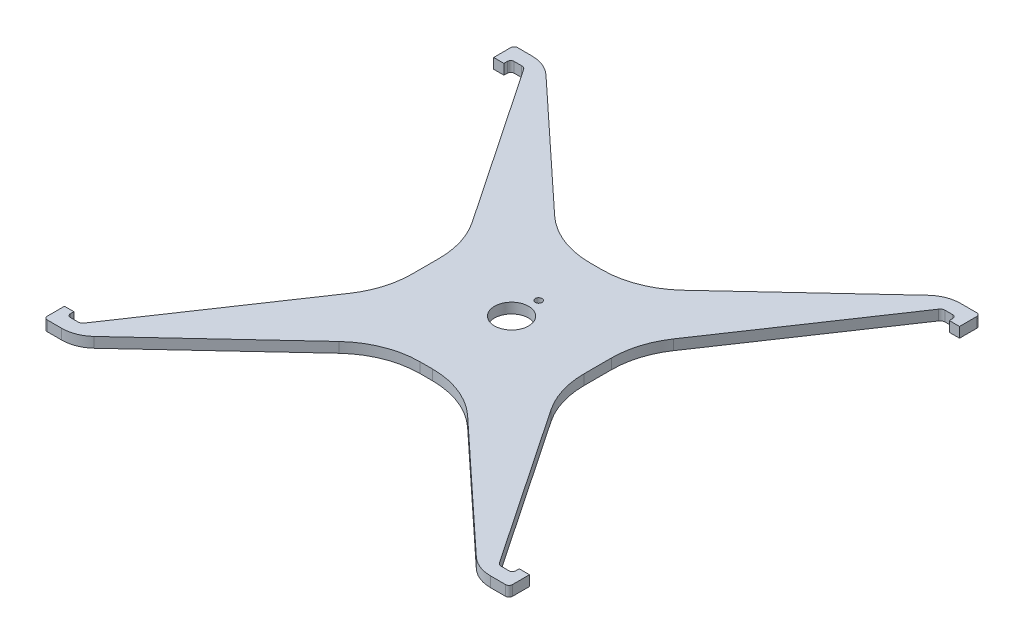
from build123d import *

# Parameters (mm, degrees)
SKETCH1_R           = 5
SKETCH1_R_2         = 1
BOSS_EXTRUDE1_DEPTH = 3


with BuildPart() as part:
    # Sketch1 → Boss-Extrude1 (new body)
    with BuildSketch(Plane(origin=(0, 0, 0), x_dir=(1, 0, 0), z_dir=(0, 1, 0))):
        with BuildLine():
            Line((-65.25, 63), (-68.25, 63))
            Line((-68.25, 63), (-68.25, 68))
            ThreePointArc((-68.25, 68), (-67.957106781, 68.707106781), (-67.25, 69))
            Line((-67.25, 69), (-63.058671293, 69))
            ThreePointArc((-63.058671293, 69), (-59.396555712, 68.305316194), (-56.243242609, 66.317781894))
            Line((-56.243242609, 66.317781894), (-19.079799162, 31.705545266))
            ThreePointArc((-19.079799162, 31.705545266), (-11.196516404, 26.736709515), (-2.04122745, 25))
            Line((-2.04122745, 25), (1.54122745, 25))
            ThreePointArc((1.54122745, 25), (10.696516404, 26.736709515), (18.579799162, 31.705545266))
            Line((18.579799162, 31.705545266), (55.743242609, 66.317781894))
            ThreePointArc((55.743242609, 66.317781894), (58.896555712, 68.305316194), (62.558671293, 69))
            Line((62.558671293, 69), (67.25, 69))
            ThreePointArc((67.25, 69), (67.957106781, 68.707106781), (68.25, 68))
            Line((68.25, 68), (68.25, 63))
            Line((68.25, 63), (65.25, 63))
            Line((65.25, 63), (65.25, 64))
            ThreePointArc((65.25, 64), (64.957106781, 64.707106781), (64.25, 65))
            Line((64.25, 65), (62.047564147, 65))
            ThreePointArc((62.047564147, 65), (61.343356803, 64.824421389), (60.804007789, 64.338789355))
            Line((60.804007789, 64.338789355), (29.524060686, 17.964360684))
            ThreePointArc((29.524060686, 17.964360684), (26.342381101, 11.293830715), (25.25, 3.984538097))
            Line((25.25, 3.984538097), (25.25, -3.984538097))
            ThreePointArc((25.25, -3.984538097), (26.342381101, -11.293830715), (29.524060686, -17.964360684))
            Line((29.524060686, -17.964360684), (60.804007789, -64.338789355))
            ThreePointArc((60.804007789, -64.338789355), (61.343356803, -64.824421389), (62.047564147, -65))
            Line((62.047564147, -65), (64.25, -65))
            ThreePointArc((64.25, -65), (64.957106781, -64.707106781), (65.25, -64))
            Line((65.25, -64), (65.25, -63))
            Line((65.25, -63), (68.25, -63))
            Line((68.25, -63), (68.25, -68))
            ThreePointArc((68.25, -68), (67.957106781, -68.707106781), (67.25, -69))
            Line((67.25, -69), (62.808671293, -69))
            ThreePointArc((62.808671293, -69), (59.146555712, -68.305316194), (55.993242609, -66.317781894))
            Line((55.993242609, -66.317781894), (18.829799162, -31.705545266))
            ThreePointArc((18.829799162, -31.705545266), (10.946516404, -26.736709515), (1.79122745, -25))
            Line((1.79122745, -25), (-1.79122745, -25))
            ThreePointArc((-1.79122745, -25), (-10.946516404, -26.736709515), (-18.829799162, -31.705545266))
            Line((-18.829799162, -31.705545266), (-55.993242609, -66.317781894))
            ThreePointArc((-55.993242609, -66.317781894), (-59.146555712, -68.305316194), (-62.808671293, -69))
            Line((-62.808671293, -69), (-67, -69))
            ThreePointArc((-67, -69), (-67.707106781, -68.707106781), (-68, -68))
            Line((-68, -68), (-68, -63))
            Line((-68, -63), (-65.25, -63))
            Line((-65.25, -63), (-65.25, -64))
            ThreePointArc((-65.25, -64), (-64.957106781, -64.707106781), (-64.25, -65))
            Line((-64.25, -65), (-62.047564147, -65))
            ThreePointArc((-62.047564147, -65), (-61.343356803, -64.824421389), (-60.804007789, -64.338789355))
            Line((-60.804007789, -64.338789355), (-29.524060686, -17.964360684))
            ThreePointArc((-29.524060686, -17.964360684), (-26.342381101, -11.293830715), (-25.25, -3.984538097))
            Line((-25.25, -3.984538097), (-25.25, 3.984538097))
            ThreePointArc((-25.25, 3.984538097), (-26.342381101, 11.293830715), (-29.524060686, 17.964360684))
            Line((-29.524060686, 17.964360684), (-60.804007789, 64.338789355))
            ThreePointArc((-60.804007789, 64.338789355), (-61.343356803, 64.824421389), (-62.047564147, 65))
            Line((-62.047564147, 65), (-64.25, 65))
            ThreePointArc((-64.25, 65), (-64.957106781, 64.707106781), (-65.25, 64))
            Line((-65.25, 64), (-65.25, 63))
        make_face()
        Circle(SKETCH1_R, mode=Mode.SUBTRACT)
        with Locations((0, 7.92)):
            Circle(SKETCH1_R_2, mode=Mode.SUBTRACT)
    extrude(amount=BOSS_EXTRUDE1_DEPTH)


solid = part.part
